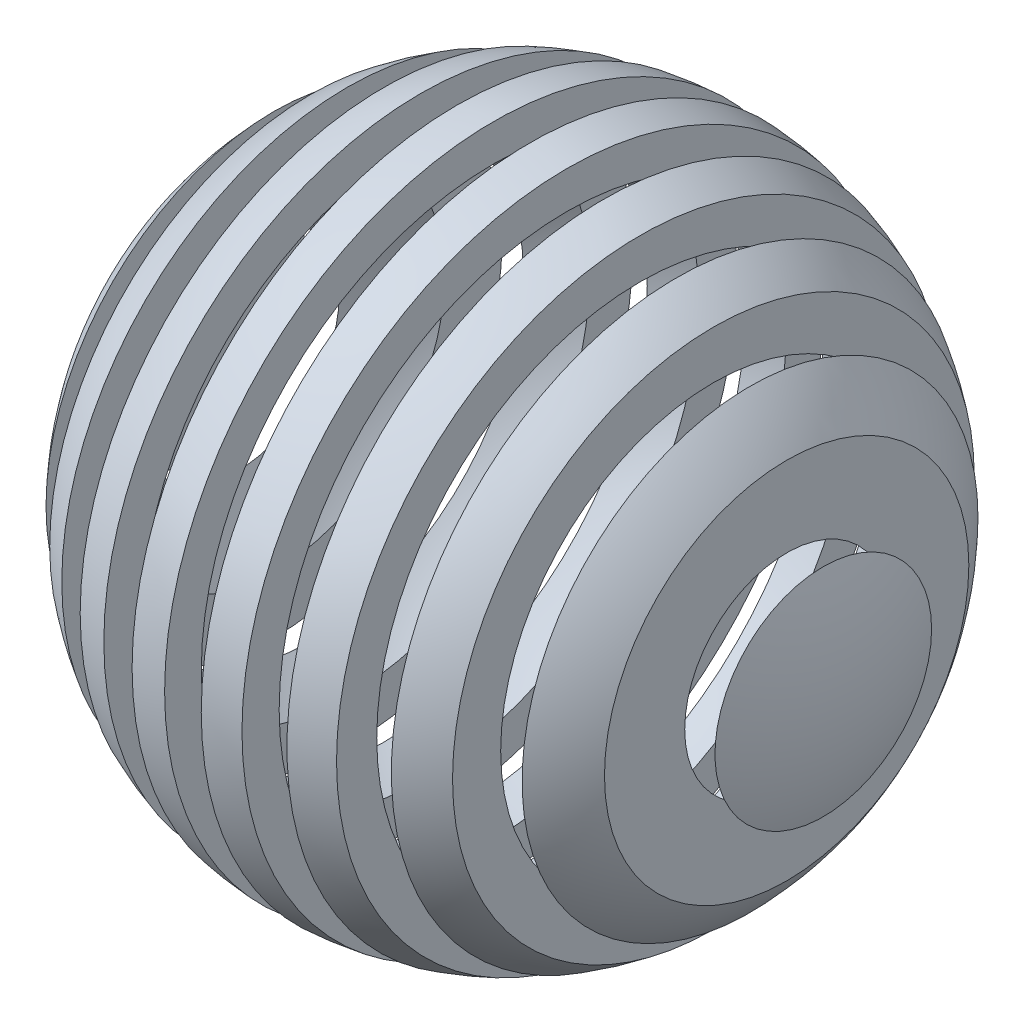
from build123d import *

# Parameters (mm, degrees)
SKETCH2_W           = 50
SKETCH2_H           = 976.29030082
CUT_EXTRUDE1_DEPTH  = 451
LPATTERN1_COUNT     = 5
LPATTERN1_PITCH     = 100
LPATTERN1_COL_COUNT = 5
LPATTERN1_COL_PITCH = 100


with BuildPart() as part:
    # Sketch1 → Revolve2 (revolve)
    with BuildSketch(Plane.XY):
        with BuildLine():
            Line((-450, 0), (-400, 0))
            ThreePointArc((-400, 0), (0, 400), (400, 0))
            Line((400, 0), (450, 0))
            ThreePointArc((450, 0), (0, 450), (-450, 0))
        make_face()
    revolve(axis=Axis((-450, 0, 0), (1, 0, 0)))

    # Sketch2 → Cut-Extrude1 (cut, symmetric)
    with BuildSketch(Plane.XY):
        Rectangle(SKETCH2_W, SKETCH2_H)
    cut_extrude1 = extrude(amount=CUT_EXTRUDE1_DEPTH, both=True, mode=Mode.SUBTRACT)

    # LPattern1: Cut-Extrude1 ×5
    with Locations(*[(-i * LPATTERN1_PITCH, 0, 0) for i in range(1, LPATTERN1_COUNT)]):
        add(cut_extrude1, mode=Mode.SUBTRACT)

    # LPattern1 col: Cut-Extrude1 ×5
    with Locations(*[(i * LPATTERN1_COL_PITCH, 0, 0) for i in range(1, LPATTERN1_COL_COUNT)]):
        add(cut_extrude1, mode=Mode.SUBTRACT)


solid = part.part
